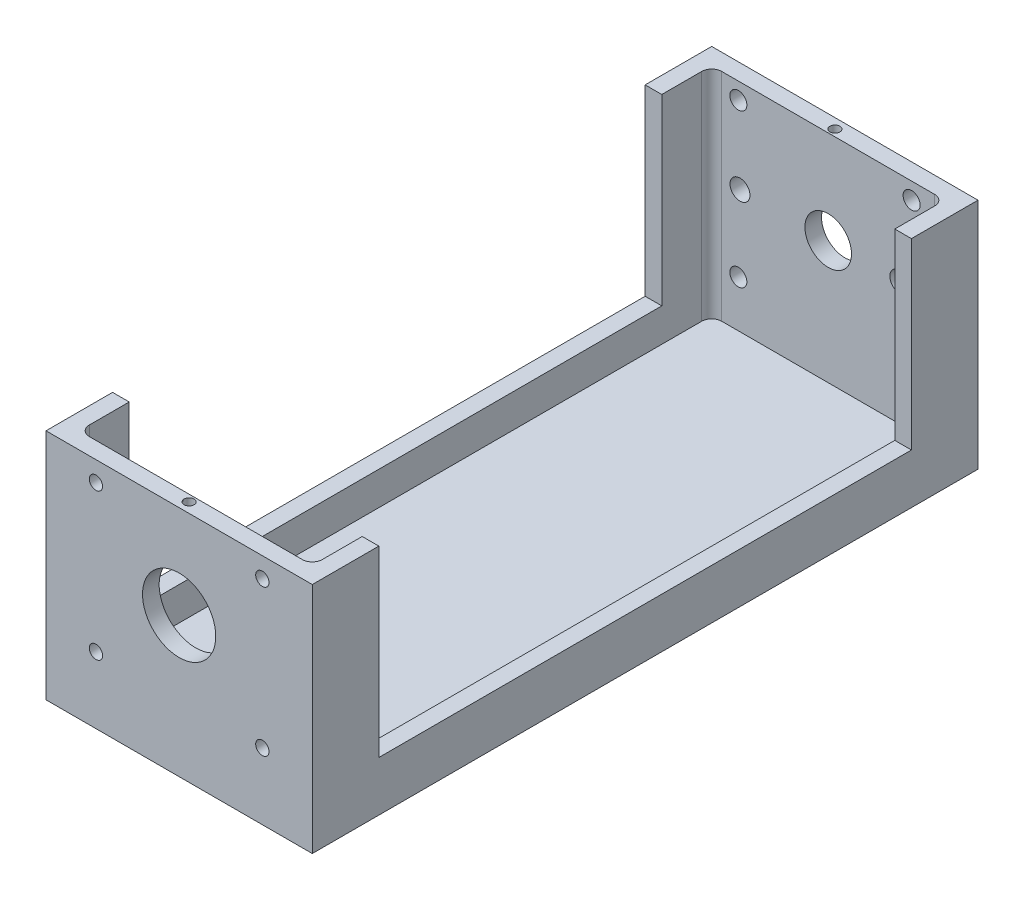
from build123d import *

# Parameters (mm, degrees)
SKETCH_1_W           = 80
SKETCH_1_H           = 70
EXTRUDE_1_DEPTH      = 200
CUT_EXTRUDE_1_DEPTH  = 65
SKETCH_3_R           = 11
CUT_EXTRUDE_2_DEPTH  = 10
SKETCH_4_R           = 2
SKETCH_4_W           = 27
SKETCH_4_H           = 36
CUT_EXTRUDE_3_DEPTH  = 10
SKETCH_7_R           = 1.5
CUT_EXTRUDE_6_DEPTH  = 10
SKETCH_8_W           = 160
SKETCH_8_H           = 55
CUT_EXTRUDE_7_DEPTH  = 81
SKETCH_10_R          = 7
CUT_EXTRUDE_9_DEPTH  = 10
SKETCH_11_R          = 3
CUT_EXTRUDE_10_DEPTH = 10
SKETCH_12_R          = 2.555087711
CUT_EXTRUDE_11_DEPTH = 10
SKETCH_13_R          = 2
CUT_EXTRUDE_12_DEPTH = 20


with BuildPart() as part:
    # 草图1 → 凸台-拉伸1 (new body)
    with BuildSketch(Plane.XY):
        Rectangle(SKETCH_1_W, SKETCH_1_H)
    extrude(amount=-EXTRUDE_1_DEPTH)

    # 草图2 → 切除-拉伸1 (cut)
    with BuildSketch(Plane(origin=(0, 35, 0), x_dir=(1, 0, 0), z_dir=(0, 1, 0))):
        with BuildLine():
            ThreePointArc((-35, 192), (-34.121320344, 194.121320344), (-32, 195))
            Line((-32, 195), (32, 195))
            ThreePointArc((32, 195), (34.121320344, 194.121320344), (35, 192))
            Line((35, 192), (35, 8))
            ThreePointArc((35, 8), (34.121320344, 5.878679656), (32, 5))
            Line((32, 5), (-32, 5))
            ThreePointArc((-32, 5), (-34.121320344, 5.878679656), (-35, 8))
            Line((-35, 8), (-35, 192))
        make_face()
    extrude(amount=-CUT_EXTRUDE_1_DEPTH, mode=Mode.SUBTRACT)

    # 草图3 → 切除-拉伸2 (cut)
    with BuildSketch(Plane.XY):
        with Locations((0, 7)):
            Circle(SKETCH_3_R)
    extrude(amount=-CUT_EXTRUDE_2_DEPTH, mode=Mode.SUBTRACT)

    # 草图4 → 切除-拉伸3 (cut)
    with BuildSketch(Plane.ZY.offset(40)):
        with Locations((-121.5, 2)):
            Circle(SKETCH_4_R)
        with Locations((-121.5, 26)):
            Circle(SKETCH_4_R)
        with Locations((-158.5, 26)):
            Circle(SKETCH_4_R)
        with Locations((-158.5, 2)):
            Circle(SKETCH_4_R)
        with Locations((-140, 14)):
            Rectangle(SKETCH_4_W, SKETCH_4_H)
    extrude(amount=-CUT_EXTRUDE_3_DEPTH, mode=Mode.SUBTRACT)

    # 草图7 → 切除-拉伸6 (cut)
    with BuildSketch(Plane(origin=(0, 35, 0), x_dir=(1, 0, 0), z_dir=(0, 1, 0))):
        with Locations((-37, 150)):
            Circle(SKETCH_7_R)
        with Locations((-37, 50)):
            Circle(SKETCH_7_R)
        with Locations((37, 50)):
            Circle(SKETCH_7_R)
        with Locations((37, 150)):
            Circle(SKETCH_7_R)
        with Locations((0, 197)):
            Circle(SKETCH_7_R)
        with Locations((0, 3)):
            Circle(SKETCH_7_R)
    extrude(amount=-CUT_EXTRUDE_6_DEPTH, mode=Mode.SUBTRACT)

    # 草图8 → 切除-拉伸7 (cut, through all)
    with BuildSketch(Plane(origin=(40, 0, 0), x_dir=(0, 0, -1), z_dir=(1, 0, 0))):
        with Locations((100, 7.5)):
            Rectangle(SKETCH_8_W, SKETCH_8_H)
    extrude(amount=-CUT_EXTRUDE_7_DEPTH, mode=Mode.SUBTRACT)

    # 草图10 → 切除-拉伸9 (cut)
    with BuildSketch(Plane(origin=(0, 0, -200), x_dir=(-1, 0, 0), z_dir=(0, 0, -1))):
        with Locations((0, 7)):
            Circle(SKETCH_10_R)
    extrude(amount=-CUT_EXTRUDE_9_DEPTH, mode=Mode.SUBTRACT)

    # 草图11 → 切除-拉伸10 (cut)
    with BuildSketch(Plane(origin=(0, 0, -200), x_dir=(-1, 0, 0), z_dir=(0, 0, -1))):
        with Locations((-21.5, 7)):
            Circle(SKETCH_11_R)
        with Locations((26.5, 7)):
            Circle(SKETCH_11_R)
    extrude(amount=-CUT_EXTRUDE_10_DEPTH, mode=Mode.SUBTRACT)

    # 草图12 → 切除-拉伸11 (cut)
    with BuildSketch(Plane(origin=(0, 0, -200), x_dir=(-1, 0, 0), z_dir=(0, 0, -1))):
        with Locations((-25.052626778, -16)):
            Circle(SKETCH_12_R)
        with Locations((-25.052626778, 30)):
            Circle(SKETCH_12_R)
        with Locations((27, 30)):
            Circle(SKETCH_12_R)
        with Locations((27, -16)):
            Circle(SKETCH_12_R)
    extrude(amount=-CUT_EXTRUDE_11_DEPTH, mode=Mode.SUBTRACT)

    # 草图13 → 切除-拉伸12 (cut)
    with BuildSketch(Plane.XY):
        with Locations((25, -15)):
            Circle(SKETCH_13_R)
        with Locations((25, 29)):
            Circle(SKETCH_13_R)
        with Locations((-25, 29)):
            Circle(SKETCH_13_R)
        with Locations((-25, -15)):
            Circle(SKETCH_13_R)
    extrude(amount=-CUT_EXTRUDE_12_DEPTH, mode=Mode.SUBTRACT)


solid = part.part
